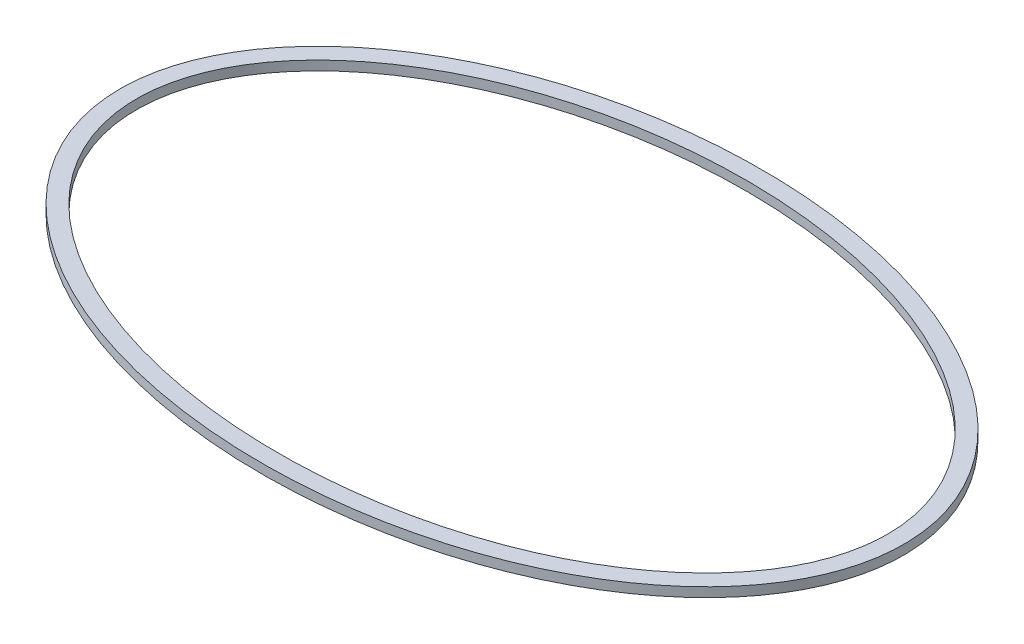
from build123d import *

# Parameters (mm, degrees)
SKETCH1_RX          = 208.983267456
SKETCH1_RY          = 134.001971305
SKETCH1_RX_2        = 200.000720375
SKETCH1_RY_2        = 125.000450235
BOSS_EXTRUDE1_DEPTH = 5


with BuildPart() as part:
    # Sketch1 → Boss-Extrude1 (new body)
    with BuildSketch(Plane(origin=(0, 0, 0), x_dir=(1, 0, 0), z_dir=(0, 1, 0))):
        with Locations(Location((-105.495636859, 43.458554402), (0, 0, -0.310784611))):
            Ellipse(SKETCH1_RX, SKETCH1_RY)
        with Locations(Location((-105.495636859, 43.458554402), (0, 0, -0.153780552))):
            Ellipse(SKETCH1_RX_2, SKETCH1_RY_2, mode=Mode.SUBTRACT)
    extrude(amount=BOSS_EXTRUDE1_DEPTH)


solid = part.part
